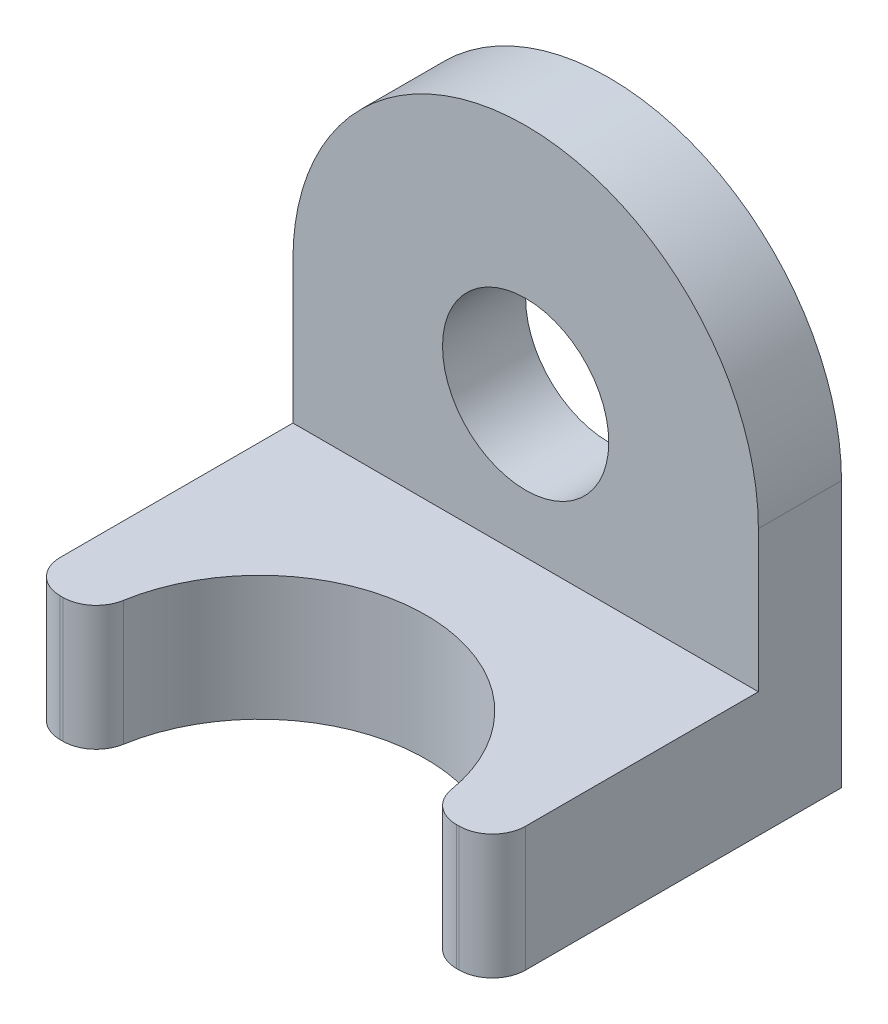
from build123d import *

# Parameters (mm, degrees)
SKETCH1_R           = 3.175
BOSS_EXTRUDE1_DEPTH = 3.175
SKETCH2_W           = 17.78
SKETCH2_H           = 4.7625
BOSS_EXTRUDE2_DEPTH = 10.16
SKETCH3_R           = 6.35
CUT_EXTRUDE1_DEPTH  = 17.78
FILLET2_R           = 1.27
FILLET3_R           = 1.27


with BuildPart() as part:
    # Sketch1 → Boss-Extrude1 (new body)
    with BuildSketch(Plane.XY):
        with BuildLine():
            Line((-8.89, 0), (-8.89, -10.16))
            Line((-8.89, -10.16), (8.89, -10.16))
            Line((8.89, -10.16), (8.89, 0))
            ThreePointArc((8.89, 0), (0, 8.89), (-8.89, 0))
        make_face()
        Circle(SKETCH1_R, mode=Mode.SUBTRACT)
    extrude(amount=BOSS_EXTRUDE1_DEPTH)

    # Sketch2 → Boss-Extrude2 (add)
    with BuildSketch(Plane.XY.offset(3.175)):
        with Locations((0, -7.77875)):
            Rectangle(SKETCH2_W, SKETCH2_H)
    extrude(amount=BOSS_EXTRUDE2_DEPTH)

    # Sketch3 → Cut-Extrude1 (cut)
    with BuildSketch(Plane(origin=(0, -10.16, 0), x_dir=(-1, 0, 0), z_dir=(0, -1, 0))):
        with Locations((0, -13.335)):
            Circle(SKETCH3_R)
    extrude(amount=-CUT_EXTRUDE1_DEPTH, mode=Mode.SUBTRACT)

    # Fillet2
    fillet2_edges = [part.edges().sort_by_distance(p)[0] for p in [
        (-8.89, -7.77875, 13.335),
        (8.89, -7.77875, 13.335),
    ]]
    fillet(fillet2_edges, radius=FILLET2_R)

    # Fillet3
    fillet3_edges = [part.edges().sort_by_distance(p)[0] for p in [
        (-6.35, -7.77875, 13.335),
        (6.35, -7.77875, 13.335),
    ]]
    fillet(fillet3_edges, radius=FILLET3_R)


solid = part.part
